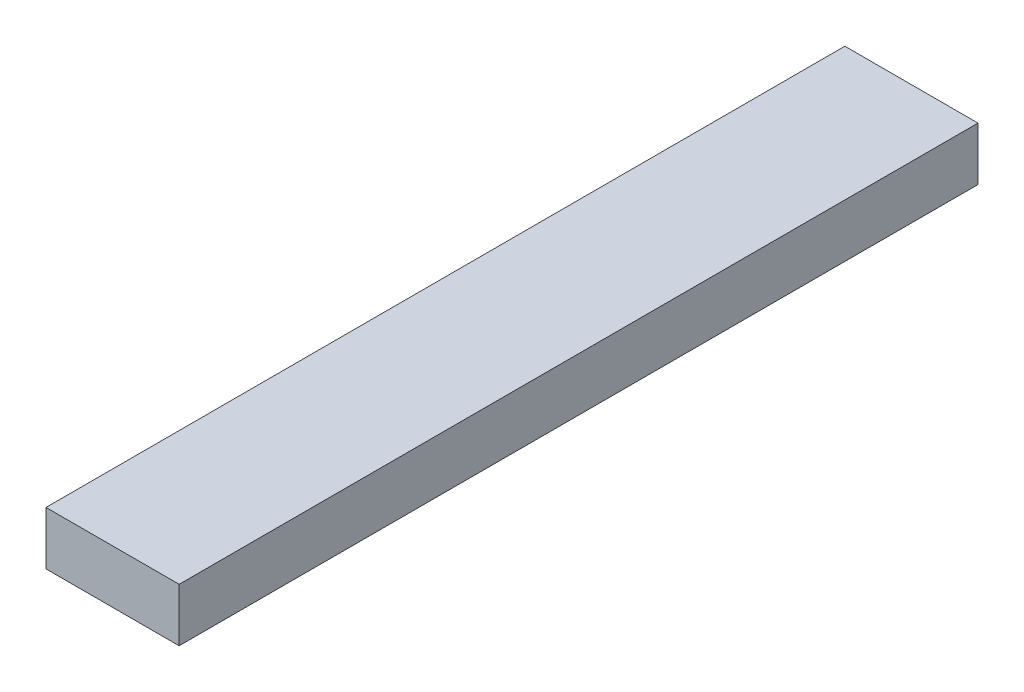
from build123d import *

# Parameters (mm, degrees)
SKETCH1_W           = 5
SKETCH1_H           = 30
BOSS_EXTRUDE1_DEPTH = 2


with BuildPart() as part:
    # Sketch1 → Boss-Extrude1 (new body)
    with BuildSketch(Plane(origin=(0, 0, 0), x_dir=(1, 0, 0), z_dir=(0, 1, 0))):
        with Locations((2.5, 15)):
            Rectangle(SKETCH1_W, SKETCH1_H)
    extrude(amount=BOSS_EXTRUDE1_DEPTH)


solid = part.part
